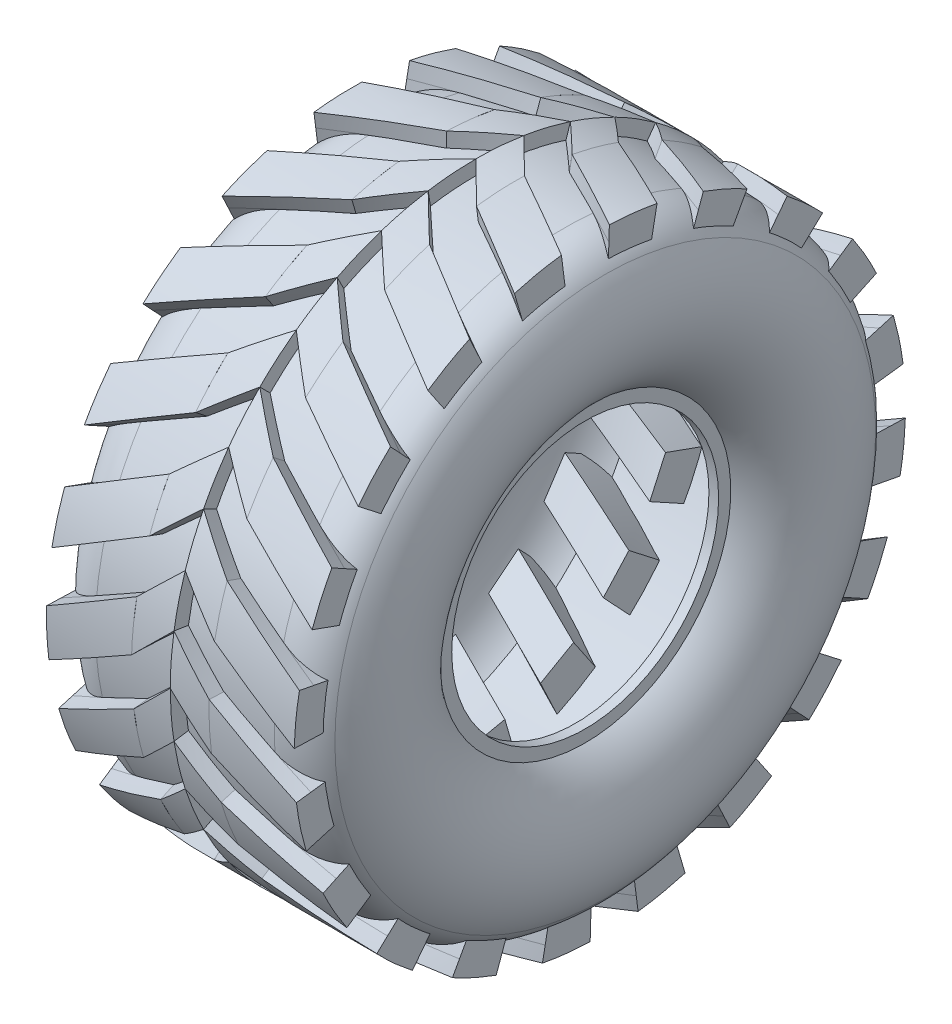
from build123d import *

# Parameters (mm, degrees)
REDONDEO1_R         = 10
BARRER1_PITCH       = 400
BARRER1_HEIGHT      = 8
BARRER1_RADIUS      = 60
BARRER1_START_ANGLE = 180
BARRER2_PITCH       = 700
BARRER2_HEIGHT      = 17.5
BARRER2_RADIUS      = 60
BARRER2_START_ANGLE = -90
MATRIZC2_COUNT      = 2
MATRIZC2_ANGLE      = 9
MATRIZC3_COUNT      = 20
MATRIZC3_2_COUNT    = 20
MATRIZC3_3_COUNT    = 20
MATRIZC3_4_COUNT    = 20


with BuildPart() as part:
    # Croquis2 → Revolución1 (revolve)
    with BuildSketch(Plane.XY, mode=Mode.PRIVATE) as revoluci_n1_sk:
        with BuildLine():
            Line((-20.5, 29.5), (-20.5, 31.035759956))
            ThreePointArc((-20.5, 31.035759956), (-27.980197774, 44.185762665), (-21.812315087, 58))
            Line((-21.812315087, 58), (0, 58))
            Line((0, 58), (21.812315087, 58))
            ThreePointArc((21.812315087, 58), (27.980197774, 44.185762665), (20.5, 31.035759956))
            Line((20.5, 31.035759956), (20.5, 29.5))
            Line((20.5, 29.5), (20.5, 27.5))
            Line((20.5, 27.5), (22.5, 27.5))
            Line((22.5, 27.5), (22.5, 30))
            ThreePointArc((22.5, 30), (30, 45), (22.5, 60))
            Line((22.5, 60), (0, 60))
            Line((0, 60), (-22.5, 60))
            ThreePointArc((-22.5, 60), (-30, 45), (-22.5, 30))
            Line((-22.5, 30), (-22.5, 27.5))
            Line((-22.5, 27.5), (-20.5, 27.5))
            Line((-20.5, 27.5), (-20.5, 29.5))
        make_face()
    revolve(revoluci_n1_sk.sketch.rotate(Axis((0, 0, 0), (1, 0, 0)), 90), axis=Axis((0, 0, 0), (1, 0, 0)))

    # Redondeo1
    redondeo1_edges = [part.edges().sort_by_distance(p)[0] for p in [
        (-22.5, 0, -60),
        (22.5, 0, -60),
    ]]
    fillet(redondeo1_edges, radius=REDONDEO1_R)


with BuildPart() as body_2:
    # Barrer1: sweep along a helix
    with BuildLine() as barrer1_path:
        add(Helix(BARRER1_PITCH, BARRER1_HEIGHT, BARRER1_RADIUS, center=(0, 0, 0), direction=(-1, 0, 0), lefthand=True, mode=Mode.PRIVATE).rotate(Axis((0, 0, 0), (-1, 0, 0)), BARRER1_START_ANGLE))
    # Croquis6 → Barrer1 (sweep)
    with BuildSketch(Plane(origin=(0, 0, 0), x_dir=(0, 0, -1), z_dir=(1, 0, 0))):
        with BuildLine():
            Line((0, 63), (0, 60))
            ThreePointArc((0, 60), (-4.707545744, 59.815040024), (-9.386067902, 59.261300436))
            Line((-9.386067902, 59.261300436), (-9.855371298, 62.224365457))
            ThreePointArc((-9.855371298, 62.224365457), (-4.942923031, 62.805792025), (0, 63))
        make_face()
    sweep(path=barrer1_path.line, is_frenet=True)


with BuildPart() as body_3:
    # Barrer2: sweep along a helix
    with BuildLine() as barrer2_path:
        add(Helix(BARRER2_PITCH, BARRER2_HEIGHT, BARRER2_RADIUS, center=(-7.999744131, 0, 0), direction=(-1, 0, 0), lefthand=True, mode=Mode.PRIVATE).rotate(Axis((-7.999744131, 0, 0), (-1, 0, 0)), BARRER2_START_ANGLE))
    # Croquis7 → Barrer2 (sweep)
    with BuildSketch(Plane.ZY.offset(7.999744131)):
        with BuildLine():
            Line((16.739708384, 57.617550826), (13.949776943, 48.014619891))
            Line((13.949776943, 48.014619891), (6.266895572, 49.605705518))
            Line((6.266895572, 49.605705518), (7.520249943, 59.526849747))
            Line((7.520249943, 59.526849747), (7.896256255, 62.503193016))
            add(Edge.make_bspline(
                [(17.576687816, 60.498430107), (12.815345157, 61.8816675), (7.896256255, 62.503193016)],
                knots=[0, 0, 0, 1, 1, 1], degree=2))
            Line((17.576687816, 60.498430107), (16.739708384, 57.617550826))
        make_face()
    sweep(path=barrer2_path.line, is_frenet=True)


with BuildPart() as body_4:
    # Simetría3: mirrored copy
    add(body_2.part.mirror(Plane(origin=(0, 0, 0), x_dir=(0, 0, 1), z_dir=(1, 0, 0))))


with BuildPart() as body_5:
    # Simetr_a3 2: mirrored copy
    add(body_3.part.mirror(Plane(origin=(0, 0, 0), x_dir=(0, 0, 1), z_dir=(1, 0, 0))))


with BuildPart() as matrizc2_1:
    # MatrizC2: pattern copy
    add(body_4.part.rotate(Axis((246.141974039, 0, 0), (-1, 0, 0)), 1 * MATRIZC2_ANGLE / (MATRIZC2_COUNT - 1)))

    # MatrizC3 2: MatrizC2_1 ×20 about axis
    matrizc3_2_axis = Axis((246.141974039, 0, 0), (-1, 0, 0))


with BuildPart() as matrizc2_2:
    # MatrizC2: pattern copy
    add(body_5.part.rotate(Axis((246.141974039, 0, 0), (-1, 0, 0)), 1 * MATRIZC2_ANGLE / (MATRIZC2_COUNT - 1)))

    # MatrizC3: MatrizC2_2 ×20 about axis
    matrizc3_axis = Axis((246.141974039, 0, 0), (-1, 0, 0))


with BuildPart() as matrizc2_2_1:
    add(matrizc2_2.part)
    for i in range(1, MATRIZC3_COUNT):
        add(matrizc2_2.part.rotate(matrizc3_axis, i * 360 / MATRIZC3_COUNT))


with BuildPart() as matrizc2_1_1:
    add(matrizc2_1.part)
    for i in range(1, MATRIZC3_2_COUNT):
        add(matrizc2_1.part.rotate(matrizc3_2_axis, i * 360 / MATRIZC3_2_COUNT))


with BuildPart() as body_2_1:
    add(body_2.part)

    # MatrizC3 3: body 2 ×20 about axis
    matrizc3_3_axis = Axis((246.141974039, 0, 0), (-1, 0, 0))


with BuildPart() as body_2_2:
    add(body_2_1.part)
    for i in range(1, MATRIZC3_3_COUNT):
        add(body_2_1.part.rotate(matrizc3_3_axis, i * 360 / MATRIZC3_3_COUNT))


with BuildPart() as body_3_1:
    add(body_3.part)

    # MatrizC3 4: body 3 ×20 about axis
    matrizc3_4_axis = Axis((246.141974039, 0, 0), (-1, 0, 0))


with BuildPart() as body_3_2:
    add(body_3_1.part)
    for i in range(1, MATRIZC3_4_COUNT):
        add(body_3_1.part.rotate(matrizc3_4_axis, i * 360 / MATRIZC3_4_COUNT))


solid = Compound([part.part, matrizc2_2_1.part, matrizc2_1_1.part, body_2_2.part, body_3_2.part])
